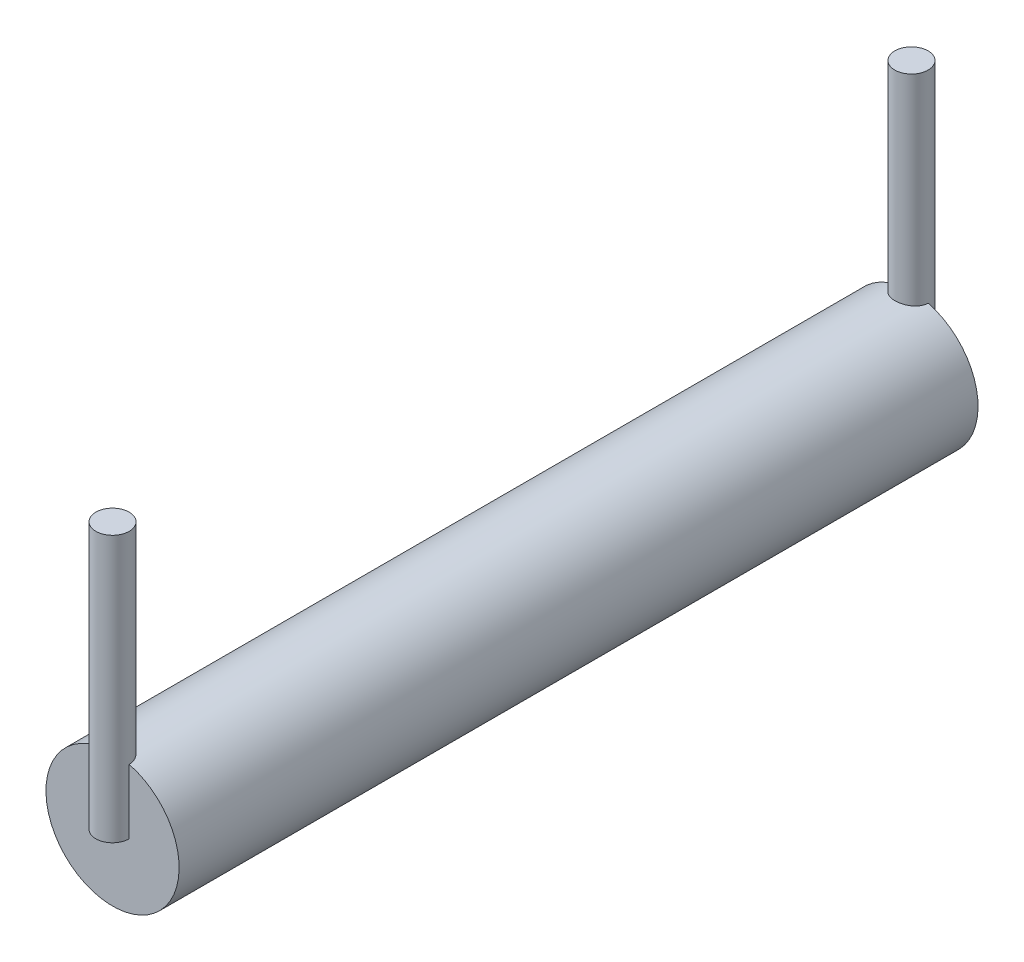
from build123d import *

# Parameters (mm, degrees)
SKETCH1_R           = 1
BOSS_EXTRUDE1_DEPTH = 6
SKETCH2_R           = 0.25
BOSS_EXTRUDE2_DEPTH = 4


with BuildPart() as part:
    # Sketch1 → Boss-Extrude1 (new body, symmetric)
    with BuildSketch(Plane.XY):
        Circle(SKETCH1_R)
    extrude(amount=BOSS_EXTRUDE1_DEPTH, both=True)

    # Sketch2 → Boss-Extrude2 (add)
    with BuildSketch(Plane(origin=(0, 0, 0), x_dir=(1, 0, 0), z_dir=(0, 1, 0))):
        with Locations((0, -6)):
            Circle(SKETCH2_R)
        with Locations((0, 6)):
            Circle(SKETCH2_R)
    extrude(amount=BOSS_EXTRUDE2_DEPTH)


solid = part.part
